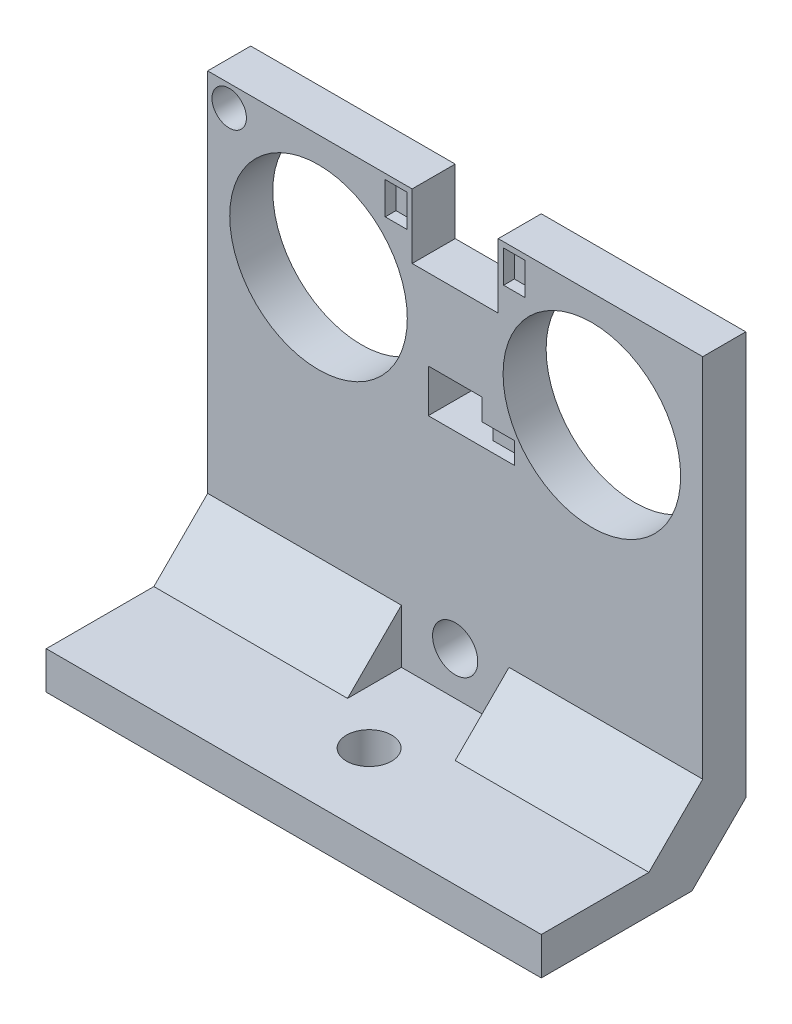
from build123d import *

# Parameters (mm, degrees)
SKETCH_1_W           = 46
SKETCH_1_H           = 20
EXTRUDE_1_DEPTH      = 4
SKETCH_2_R           = 8.25
CUT_EXTRUDE_1_DEPTH  = 5
SKETCH_3_W           = 8
SKETCH_3_H           = 6
CUT_EXTRUDE_2_DEPTH  = 5
SKETCH_4_W           = 5
SKETCH_4_H           = 4
CUT_EXTRUDE_3_DEPTH  = 5
SKETCH_5_W           = 3
SKETCH_5_H           = 2
SKETCH_5_W_2         = 2
SKETCH_5_H_2         = 3
CUT_EXTRUDE_4_DEPTH  = 1
SKETCH_6_W           = 46
SKETCH_6_H           = 4
EXTRUDE_2_DEPTH      = 22.5
SKETCH_8_W           = 15
SKETCH_8_H           = 3.5
EXTRUDE_4_DEPTH      = 46
CHAMFER_3_SIZE       = 5
SKETCH_9_R           = 2.1
CUT_EXTRUDE_5_DEPTH  = 4.5
SKETCH_10_R          = 2.1
CUT_EXTRUDE_6_DEPTH  = 20
SKETCH_13_W          = 10
SKETCH_13_H          = 8
CUT_EXTRUDE_9_DEPTH  = 46
SKETCH_14_R          = 1.6
CUT_EXTRUDE_10_DEPTH = 46


with BuildPart() as part:
    # 草圖1 → 填料-伸長1 (new body)
    with BuildSketch(Plane.XY):
        Rectangle(SKETCH_1_W, SKETCH_1_H)
    extrude(amount=EXTRUDE_1_DEPTH)

    # 草圖2 → 除料-伸長1 (cut, through all)
    with BuildSketch(Plane.XY.offset(4)):
        with Locations((-12.7, -0.65)):
            Circle(SKETCH_2_R)
        with Locations((12.7, -0.65)):
            Circle(SKETCH_2_R)
    extrude(amount=-CUT_EXTRUDE_1_DEPTH, mode=Mode.SUBTRACT)

    # 草圖3 → 除料-伸長2 (cut, through all)
    with BuildSketch(Plane.XY.offset(4)):
        with Locations((0, 7)):
            Rectangle(SKETCH_3_W, SKETCH_3_H)
    extrude(amount=-CUT_EXTRUDE_2_DEPTH, mode=Mode.SUBTRACT)

    # 草圖4 → 除料-伸長3 (cut, through all)
    with BuildSketch(Plane.XY.offset(4)):
        with Locations((0, -5.5)):
            Rectangle(SKETCH_4_W, SKETCH_4_H)
    extrude(amount=-CUT_EXTRUDE_3_DEPTH, mode=Mode.SUBTRACT)

    # 草圖5 → 除料-伸長4 (cut)
    with BuildSketch(Plane.XY.offset(4)):
        with Locations((4, -6.5)):
            Rectangle(SKETCH_5_W, SKETCH_5_H)
        with Locations((-5.5, 8)):
            Rectangle(SKETCH_5_W_2, SKETCH_5_H_2)
        with Locations((5.5, 8)):
            Rectangle(SKETCH_5_W_2, SKETCH_5_H_2)
    extrude(amount=-CUT_EXTRUDE_4_DEPTH, mode=Mode.SUBTRACT)

    # 草圖6 → 填料-伸長2 (add)
    with BuildSketch(Plane.XZ.offset(10)):
        with Locations((0, 2)):
            Rectangle(SKETCH_6_W, SKETCH_6_H)
    extrude(amount=EXTRUDE_2_DEPTH)

    # 草圖8 → 填料-伸長4 (add)
    with BuildSketch(Plane.ZY.offset(23)):
        with Locations((11.5, -30.75)):
            Rectangle(SKETCH_8_W, SKETCH_8_H)
    extrude(amount=-EXTRUDE_4_DEPTH)

    # 導角3
    chamfer_3_edges = [part.edges().sort_by_distance(p)[0] for p in [
        (0, -29, 4),
        (0, -32.5, 0),
    ]]
    chamfer(chamfer_3_edges, length=CHAMFER_3_SIZE)

    # 草圖9 → 除料-伸長5 (cut, through all)
    with BuildSketch(Plane(origin=(0, -29, 0), x_dir=(1, 0, 0), z_dir=(0, 1, 0))):
        with Locations((0, -12)):
            Circle(SKETCH_9_R)
    extrude(amount=-CUT_EXTRUDE_5_DEPTH, mode=Mode.SUBTRACT)

    # 草圖10 → 除料-伸長6 (cut, through all)
    with BuildSketch(Plane(origin=(0, 0, 0), x_dir=(-1, 0, 0), z_dir=(0, 0, -1))):
        with Locations((0, -25)):
            Circle(SKETCH_10_R)
    extrude(amount=-CUT_EXTRUDE_6_DEPTH, mode=Mode.SUBTRACT)

    # 草圖13 → 除料-伸長9 (cut)
    with BuildSketch(Plane.XY.offset(4)):
        with Locations((0, -25)):
            Rectangle(SKETCH_13_W, SKETCH_13_H)
    extrude(amount=CUT_EXTRUDE_9_DEPTH, mode=Mode.SUBTRACT)

    # 草圖14 → 除料-伸長10 (cut)
    with BuildSketch(Plane.XY.offset(4)):
        with Locations((-21, 8)):
            Circle(SKETCH_14_R)
    extrude(amount=-CUT_EXTRUDE_10_DEPTH, mode=Mode.SUBTRACT)


solid = part.part
